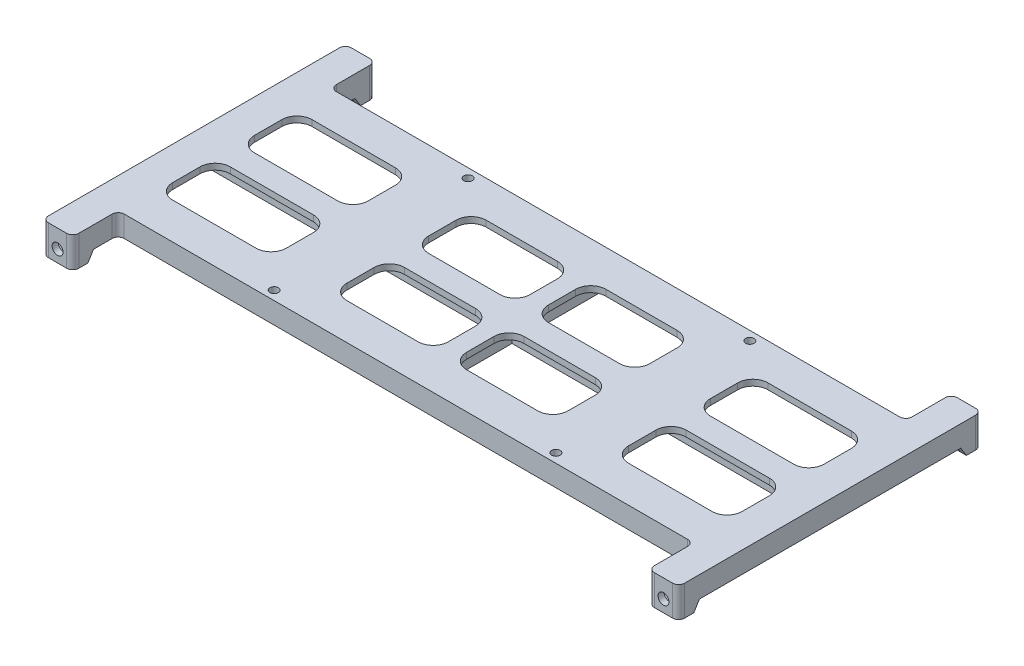
from build123d import *

# Parameters (mm, degrees)
SKETCH_1_W                                 = 210
SKETCH_1_H                                 = 100
EXTRUDE_1_DEPTH                            = 2
SKETCH_3_W                                 = 10
SKETCH_3_H                                 = 8
EXTRUDE_2_DEPTH                            = 5
SKETCH_4_R                                 = 1.8
CUT_EXTRUDE_1_DEPTH                        = 5
RIB_3_REACH                                = 218.019
SKETCH_5_WALL_W                            = 443.471016582
SKETCH_5_WALL_H                            = 2
CUT_EXTRUDE_2_DEPTH                        = 3
MIRROR_2_COPY_1_REACH                      = 218.019
MIRROR_2_COPY_1_SKETCH_W                   = 443.471016582
MIRROR_2_COPY_1_SKETCH_H                   = 2
MIRROR_2_AT_THE_SECOND_PLANE_COPY_1_REACH  = 218.019
MIRROR_2_AT_THE_SECOND_PLANE_COPY_1_SKET_W = 443.471016582
MIRROR_2_AT_THE_SECOND_PLANE_COPY_1_SKET_H = 2
MIRROR_2_AT_THE_SECOND_PLANE_COPY_2_SKET_W = 10
MIRROR_2_AT_THE_SECOND_PLANE_COPY_2_SKET_H = 8
MIRROR_2_AT_THE_SECOND_PLANE_COPY_2_DEPTH  = 5
MIRROR_2_AT_THE_SECOND_PLANE_COPY_3_SKET_R = 1.8
MIRROR_2_AT_THE_SECOND_PLANE_COPY_3_DEPTH  = 5
MIRROR_2_AT_THE_SECOND_PLANE_COPY_4_REACH  = 218.019
MIRROR_2_AT_THE_SECOND_PLANE_COPY_4_SKET_W = 443.471016582
MIRROR_2_AT_THE_SECOND_PLANE_COPY_4_SKET_H = 2
MIRROR_2_AT_THE_SECOND_PLANE_COPY_5_DEPTH  = 3
MIRROR_2_AT_THE_SECOND_PLANE_COPY_6_REACH  = 218.019
MIRROR_2_AT_THE_SECOND_PLANE_COPY_6_SKET_W = 443.471016582
MIRROR_2_AT_THE_SECOND_PLANE_COPY_6_SKET_H = 2
SKETCH_19_W                                = 190
SKETCH_19_H                                = 15
CUT_EXTRUDE_5_DEPTH                        = 117.571866246
EXTRUDE_3_DEPTH                            = 5
SKETCH_10_W                                = 2
SKETCH_10_H                                = 90
EXTRUDE_4_DEPTH                            = 5
SKETCH_11_W                                = 2
SKETCH_11_H                                = 70
EXTRUDE_5_DEPTH                            = 5
SKETCH_12_W                                = 206
SKETCH_12_H                                = 2
EXTRUDE_6_DEPTH                            = 5
SKETCH_13_R                                = 3
EXTRUDE_7_DEPTH                            = 5
SKETCH_15_R                                = 1.4
CUT_EXTRUDE_3_DEPTH                        = 117.507510488
MIRROR_4_AT_THE_SECOND_PLANE_COPY_1_SKET_R = 3
MIRROR_4_AT_THE_SECOND_PLANE_COPY_1_DEPTH  = 5
MIRROR_4_AT_THE_SECOND_PLANE_COPY_2_SKET_R = 1.4
MIRROR_4_AT_THE_SECOND_PLANE_COPY_2_DEPTH  = 117.507510488
FILLET_1_R                                 = 2
SKETCH_17_W                                = 37.5
SKETCH_17_H                                = 19
SKETCH_17_W_2                              = 33.5
CUT_EXTRUDE_4_DEPTH                        = 117.571866246
FILLET_2_R                                 = 5
FILLET_3_R                                 = 2
FILLET_4_R                                 = 4


with BuildPart() as part:
    # 草图1 → 凸台-拉伸1 (new body)
    with BuildSketch(Plane(origin=(0, 0, 0), x_dir=(1, 0, 0), z_dir=(0, 1, 0))):
        Rectangle(SKETCH_1_W, SKETCH_1_H)
    extrude(amount=EXTRUDE_1_DEPTH)

    # 草图3 → 凸台-拉伸2 (add)
    with BuildSketch(Plane.XY.offset(50)):
        with Locations((-100, -4)):
            Rectangle(SKETCH_3_W, SKETCH_3_H)
    extrude_2 = extrude(amount=-EXTRUDE_2_DEPTH)

    # 草图4 → 切除-拉伸1 (cut)
    with BuildSketch(Plane.XY.offset(50)):
        with Locations((-100, -4)):
            Circle(SKETCH_4_R)
    cut_extrude_1 = extrude(amount=-CUT_EXTRUDE_1_DEPTH, mode=Mode.SUBTRACT)

    # 草图5 wall → 筋3 (add, up to next)
    with BuildSketch(Plane(origin=(-105, -4, 42.5), x_dir=(0, -0.847998304005, 0.529998940003), z_dir=(0, 0.529998940003, 0.847998304005)), mode=Mode.PRIVATE) as rib_3_sk1:
        with Locations((0, 1)):
            Rectangle(SKETCH_5_WALL_W, SKETCH_5_WALL_H)
    rib_3_tool1 = extrude(rib_3_sk1.sketch, amount=RIB_3_REACH, mode=Mode.PRIVATE) - part.part
    rib_3 = rib_3_tool1.solids().sort_by_distance((-105, -4, 42.5))[0]
    add(rib_3)

    # 镜向1: 筋3 across plane
    add(rib_3.mirror(Plane.ZY.offset(100)))

    # 草图6 → 切除-拉伸2 (cut)
    with BuildSketch(Plane(origin=(0, 0, 45), x_dir=(-1, 0, 0), z_dir=(0, 0, -1))):
        Polygon((100, -7.233161507), (102.8, -5.616580754), (102.8, -2.383419246), (100, -0.766838493), (97.2, -2.383419246), (97.2, -5.616580754), align=None)
    cut_extrude_2 = extrude(amount=-CUT_EXTRUDE_2_DEPTH, mode=Mode.SUBTRACT)

    # 镜向2: 凸台-拉伸2, 切除-拉伸1, 筋3, 切除-拉伸2 across plane
    add(extrude_2.mirror(Plane.XY))
    add(cut_extrude_1.mirror(Plane.XY), mode=Mode.SUBTRACT)
    add(rib_3.mirror(Plane.XY))
    add(cut_extrude_2.mirror(Plane.XY), mode=Mode.SUBTRACT)

    # 镜向2 copy 1 sketch → 镜向2 copy 1 (add, up to next)
    with BuildSketch(Plane(origin=(-95, -4, -42.5), x_dir=(0, -0.847998304005, -0.529998940003), z_dir=(0, 0.529998940003, -0.847998304005)), mode=Mode.PRIVATE) as mirror_2_copy_1_sk1:
        with Locations((0, 1)):
            Rectangle(MIRROR_2_COPY_1_SKETCH_W, MIRROR_2_COPY_1_SKETCH_H)
    mirror_2_copy_1_tool1 = extrude(mirror_2_copy_1_sk1.sketch, amount=MIRROR_2_COPY_1_REACH, mode=Mode.PRIVATE) - part.part
    add(mirror_2_copy_1_tool1.solids().sort_by_distance((-95, -4, -42.5))[0])

    # 镜向2 at the second plane: 凸台-拉伸2, 切除-拉伸1, 筋3, 切除-拉伸2 across plane
    add(extrude_2.mirror(Plane(origin=(0, 0, 0), x_dir=(0, 0, 1), z_dir=(1, 0, 0))))
    add(cut_extrude_1.mirror(Plane(origin=(0, 0, 0), x_dir=(0, 0, 1), z_dir=(1, 0, 0))), mode=Mode.SUBTRACT)
    add(rib_3.mirror(Plane(origin=(0, 0, 0), x_dir=(0, 0, 1), z_dir=(1, 0, 0))))
    add(cut_extrude_2.mirror(Plane(origin=(0, 0, 0), x_dir=(0, 0, 1), z_dir=(1, 0, 0))), mode=Mode.SUBTRACT)

    # 镜向2 at the second plane copy 1 sket → 镜向2 at the second plane copy 1 (add, up to next)
    with BuildSketch(Plane(origin=(95, -4, 42.5), x_dir=(0, -0.847998304005, 0.529998940003), z_dir=(0, 0.529998940003, 0.847998304005)), mode=Mode.PRIVATE) as mirror_2_at_the_second_plane_copy_1_sk1:
        with Locations((0, 1)):
            Rectangle(MIRROR_2_AT_THE_SECOND_PLANE_COPY_1_SKET_W, MIRROR_2_AT_THE_SECOND_PLANE_COPY_1_SKET_H)
    mirror_2_at_the_second_plane_copy_1_tool1 = extrude(mirror_2_at_the_second_plane_copy_1_sk1.sketch, amount=MIRROR_2_AT_THE_SECOND_PLANE_COPY_1_REACH, mode=Mode.PRIVATE) - part.part
    add(mirror_2_at_the_second_plane_copy_1_tool1.solids().sort_by_distance((95, -4, 42.5))[0])

    # 镜向2 at the second plane copy 2 sket → 镜向2 at the second plane copy 2 (add)
    with BuildSketch(Plane(origin=(0, 0, -50), x_dir=(-1, 0, 0), z_dir=(0, 0, -1))):
        with Locations((-100, -4)):
            Rectangle(MIRROR_2_AT_THE_SECOND_PLANE_COPY_2_SKET_W, MIRROR_2_AT_THE_SECOND_PLANE_COPY_2_SKET_H)
    extrude(amount=-MIRROR_2_AT_THE_SECOND_PLANE_COPY_2_DEPTH)

    # 镜向2 at the second plane copy 3 sket → 镜向2 at the second plane copy 3 (cut)
    with BuildSketch(Plane(origin=(0, 0, -50), x_dir=(-1, 0, 0), z_dir=(0, 0, -1))):
        with Locations((-100, -4)):
            Circle(MIRROR_2_AT_THE_SECOND_PLANE_COPY_3_SKET_R)
    extrude(amount=-MIRROR_2_AT_THE_SECOND_PLANE_COPY_3_DEPTH, mode=Mode.SUBTRACT)

    # 镜向2 at the second plane copy 4 sket → 镜向2 at the second plane copy 4 (add, up to next)
    with BuildSketch(Plane(origin=(105, -4, -42.5), x_dir=(0, -0.847998304005, -0.529998940003), z_dir=(0, 0.529998940003, -0.847998304005)), mode=Mode.PRIVATE) as mirror_2_at_the_second_plane_copy_4_sk1:
        with Locations((0, 1)):
            Rectangle(MIRROR_2_AT_THE_SECOND_PLANE_COPY_4_SKET_W, MIRROR_2_AT_THE_SECOND_PLANE_COPY_4_SKET_H)
    mirror_2_at_the_second_plane_copy_4_tool1 = extrude(mirror_2_at_the_second_plane_copy_4_sk1.sketch, amount=MIRROR_2_AT_THE_SECOND_PLANE_COPY_4_REACH, mode=Mode.PRIVATE) - part.part
    add(mirror_2_at_the_second_plane_copy_4_tool1.solids().sort_by_distance((105, -4, -42.5))[0])

    # 镜向2 at the second plane copy 5 sket → 镜向2 at the second plane copy 5 (cut)
    with BuildSketch(Plane.XY.offset(-45)):
        Polygon((100, -7.233161507), (102.8, -5.616580754), (102.8, -2.383419246), (100, -0.766838493), (97.2, -2.383419246), (97.2, -5.616580754), align=None)
    extrude(amount=-MIRROR_2_AT_THE_SECOND_PLANE_COPY_5_DEPTH, mode=Mode.SUBTRACT)

    # 镜向2 at the second plane copy 6 sket → 镜向2 at the second plane copy 6 (add, up to next)
    with BuildSketch(Plane(origin=(95, -4, -42.5), x_dir=(0, -0.847998304005, -0.529998940003), z_dir=(0, 0.529998940003, -0.847998304005)), mode=Mode.PRIVATE) as mirror_2_at_the_second_plane_copy_6_sk1:
        with Locations((0, -1)):
            Rectangle(MIRROR_2_AT_THE_SECOND_PLANE_COPY_6_SKET_W, MIRROR_2_AT_THE_SECOND_PLANE_COPY_6_SKET_H)
    mirror_2_at_the_second_plane_copy_6_tool1 = extrude(mirror_2_at_the_second_plane_copy_6_sk1.sketch, amount=MIRROR_2_AT_THE_SECOND_PLANE_COPY_6_REACH, mode=Mode.PRIVATE) - part.part
    add(mirror_2_at_the_second_plane_copy_6_tool1.solids().sort_by_distance((95, -4, -42.5))[0])

    # 草图19 → 切除-拉伸5 (cut, through all)
    with BuildSketch(Plane.XZ):
        with Locations((0, 42.5)):
            Rectangle(SKETCH_19_W, SKETCH_19_H)
        with Locations((0, -42.5)):
            Rectangle(SKETCH_19_W, SKETCH_19_H)
    extrude(amount=-CUT_EXTRUDE_5_DEPTH, mode=Mode.SUBTRACT)

    # 草图7 → 凸台-拉伸3 (add)
    with BuildSketch(Plane.XZ):
        Polygon((97, 33), (97, 40), (97, 45), (95, 45), (95, 40), (95, 35), (-95, 35), (-95, 40), (-95, 45), (-97, 45), (-97, 40), (-97, 33), align=None)
        Polygon((-95, -40), (-95, -35), (95, -35), (95, -40), (95, -45), (97, -45), (97, -40), (97, -33), (-97, -33), (-97, -40), (-97, -45), (-95, -45), align=None)
    extrude(amount=EXTRUDE_3_DEPTH)

    # 草图10 → 凸台-拉伸4 (add)
    with BuildSketch(Plane.XZ):
        with Locations((-104, 0)):
            Rectangle(SKETCH_10_W, SKETCH_10_H)
    extrude_4 = extrude(amount=EXTRUDE_4_DEPTH)

    # 镜向3: 凸台-拉伸4 across plane
    add(extrude_4.mirror(Plane(origin=(0, 0, 0), x_dir=(0, 0, 1), z_dir=(1, 0, 0))))

    # 草图11 → 凸台-拉伸5 (add)
    with BuildSketch(Plane.XZ):
        Rectangle(SKETCH_11_W, SKETCH_11_H)
    extrude(amount=EXTRUDE_5_DEPTH)

    # 草图12 → 凸台-拉伸6 (add)
    with BuildSketch(Plane.XZ):
        Rectangle(SKETCH_12_W, SKETCH_12_H)
    extrude(amount=EXTRUDE_6_DEPTH)

    # 草图13 → 凸台-拉伸7 (add)
    with BuildSketch(Plane.XZ):
        with Locations((-46.5, 32)):
            Circle(SKETCH_13_R)
    extrude_7 = extrude(amount=EXTRUDE_7_DEPTH)

    # 草图15 → 切除-拉伸3 (cut, through all)
    with BuildSketch(Plane.XZ.offset(5)):
        with Locations(Location((-46.5, 32, 0), (0, 0, 270))):
            Circle(SKETCH_15_R)
    cut_extrude_3 = extrude(amount=-CUT_EXTRUDE_3_DEPTH, mode=Mode.SUBTRACT)

    # 镜向4: 凸台-拉伸7, 切除-拉伸3 across plane
    add(extrude_7.mirror(Plane(origin=(0, 0, 0), x_dir=(0, 0, 1), z_dir=(1, 0, 0))))
    add(cut_extrude_3.mirror(Plane(origin=(0, 0, 0), x_dir=(0, 0, 1), z_dir=(1, 0, 0))), mode=Mode.SUBTRACT)

    # 镜向4 at the second plane: 凸台-拉伸7, 切除-拉伸3 across plane
    add(extrude_7.mirror(Plane.XY))
    add(cut_extrude_3.mirror(Plane.XY), mode=Mode.SUBTRACT)

    # 镜向4 at the second plane copy 1 sket → 镜向4 at the second plane copy 1 (add)
    with BuildSketch(Plane(origin=(0, 0, 0), x_dir=(-1, 0, 0), z_dir=(0, -1, 0))):
        with Locations((-46.5, 32)):
            Circle(MIRROR_4_AT_THE_SECOND_PLANE_COPY_1_SKET_R)
    extrude(amount=MIRROR_4_AT_THE_SECOND_PLANE_COPY_1_DEPTH)

    # 镜向4 at the second plane copy 2 sket → 镜向4 at the second plane copy 2 (cut, through all)
    with BuildSketch(Plane(origin=(0, -5, 0), x_dir=(-1, 0, 0), z_dir=(0, -1, 0))):
        with Locations(Location((-46.5, 32, 0), (0, 0, 270))):
            Circle(MIRROR_4_AT_THE_SECOND_PLANE_COPY_2_SKET_R)
    extrude(amount=-MIRROR_4_AT_THE_SECOND_PLANE_COPY_2_DEPTH, mode=Mode.SUBTRACT)

    # 圆角1
    fillet_1_edges = [part.edges().sort_by_distance(p)[0] for p in [
        (105, -3, 50),
        (-105, -3, 50),
        (-105, -3, -50),
        (105, -3, -50),
    ]]
    fillet(fillet_1_edges, radius=FILLET_1_R)

    # 草图17 → 切除-拉伸4 (cut, through all)
    with BuildSketch(Plane.XZ):
        with Locations((-75.25, 13.5)):
            Rectangle(SKETCH_17_W, SKETCH_17_H)
        with Locations((75.25, 13.5)):
            Rectangle(SKETCH_17_W, SKETCH_17_H)
        with Locations((75.25, -13.5)):
            Rectangle(SKETCH_17_W, SKETCH_17_H)
        with Locations((-75.25, -13.5)):
            Rectangle(SKETCH_17_W, SKETCH_17_H)
        with Locations((-19.75, 13.5)):
            Rectangle(SKETCH_17_W_2, SKETCH_17_H)
        with Locations((19.75, 13.5)):
            Rectangle(SKETCH_17_W_2, SKETCH_17_H)
        with Locations((19.75, -13.5)):
            Rectangle(SKETCH_17_W_2, SKETCH_17_H)
        with Locations((-19.75, -13.5)):
            Rectangle(SKETCH_17_W_2, SKETCH_17_H)
    extrude(amount=-CUT_EXTRUDE_4_DEPTH, mode=Mode.SUBTRACT)

    # 圆角2
    fillet_2_edges = [part.edges().sort_by_distance(p)[0] for p in [
        (56.5, 1, 23),
        (94, 1, 23),
        (94, 1, 4),
        (56.5, 1, 4),
        (94, 1, -4),
        (94, 1, -23),
        (56.5, 1, -23),
        (56.5, 1, -4),
        (-56.5, 1, -23),
        (-94, 1, -23),
        (-94, 1, -4),
        (-56.5, 1, -4),
        (-36.5, 1, 4),
        (-36.5, 1, 23),
        (-3, 1, 23),
        (-3, 1, 4),
        (3, 1, 23),
        (36.5, 1, 23),
        (36.5, 1, 4),
        (3, 1, 4),
        (36.5, 1, -4),
        (36.5, 1, -23),
        (3, 1, -23),
        (3, 1, -4),
        (-3, 1, -23),
        (-36.5, 1, -23),
        (-36.5, 1, -4),
        (-3, 1, -4),
        (-94, 1, 4),
        (-94, 1, 23),
        (-56.5, 1, 23),
        (-56.5, 1, 4),
    ]]
    fillet(fillet_2_edges, radius=FILLET_2_R)

    # 圆角3
    fillet_3_edges = [part.edges().sort_by_distance(p)[0] for p in [
        (95, -3, 50),
        (-95, -3, -50),
        (95, -3, -50),
        (-95, -3, 50),
        (-95, -1.5, 35),
        (95, -1.5, 35),
        (-95, -1.5, -35),
        (95, -1.5, -35),
    ]]
    fillet(fillet_3_edges, radius=FILLET_3_R)

    # 圆角4
    fillet_4_edges = [part.edges().sort_by_distance(p)[0] for p in [
        (-97, -2.5, 33),
        (97, -2.5, 33),
        (97, -2.5, -33),
        (-97, -2.5, -33),
    ]]
    fillet(fillet_4_edges, radius=FILLET_4_R)


solid = part.part
